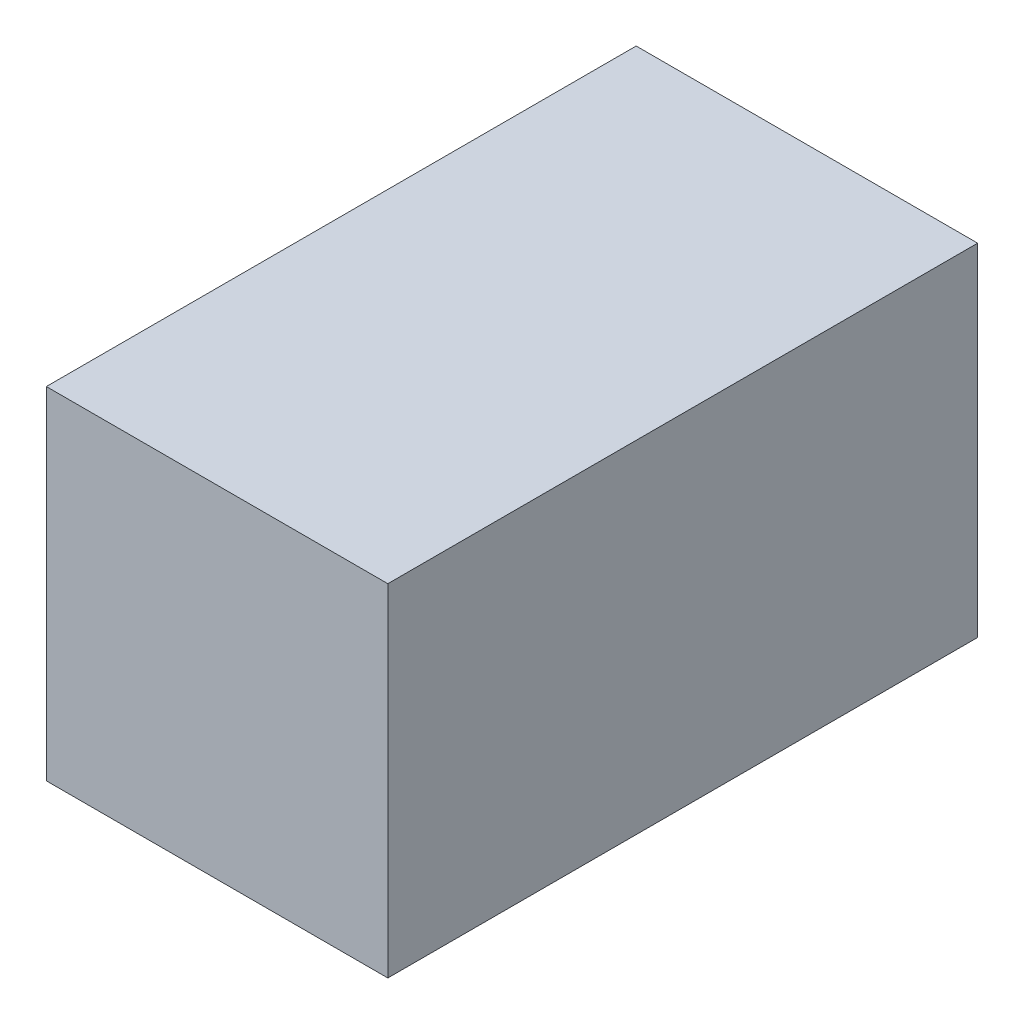
from build123d import *

# Parameters (mm, degrees)
ESQUISSE1_W        = 55
ESQUISSE1_H        = 55
BOSS_EXTRU_2_DEPTH = 95


with BuildPart() as part:
    # Esquisse1 → Boss.-Extru.2 (new body)
    with BuildSketch(Plane.XY):
        Rectangle(ESQUISSE1_W, ESQUISSE1_H)
    extrude(amount=BOSS_EXTRU_2_DEPTH)


solid = part.part
